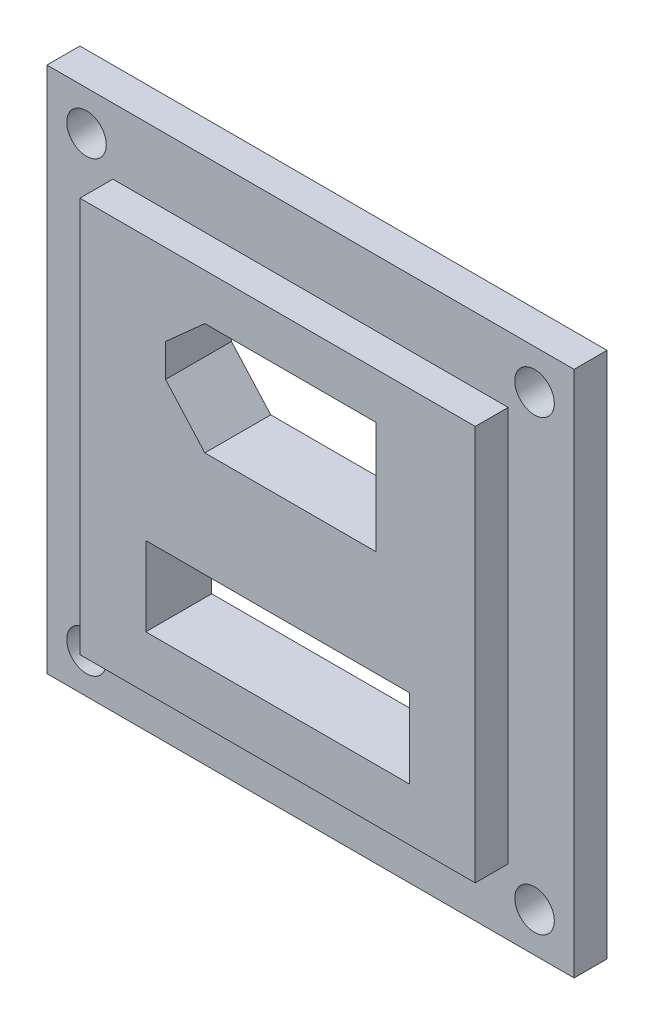
from build123d import *

# Parameters (mm, degrees)
SKETCH1_W           = 40
SKETCH1_H           = 40
BOSS_EXTRUDE2_DEPTH = 2.5
SKETCH2_W           = 30
SKETCH2_H           = 30
BOSS_EXTRUDE3_DEPTH = 2.5
SKETCH3_R           = 1.5
CUT_EXTRUDE1_DEPTH  = 2.5
SKETCH4_W           = 20
SKETCH4_H           = 6
CUT_EXTRUDE2_DEPTH  = 5


with BuildPart() as part:
    # Sketch1 → Boss-Extrude2 (new body)
    with BuildSketch(Plane.XY):
        with Locations((20, 20)):
            Rectangle(SKETCH1_W, SKETCH1_H)
    extrude(amount=BOSS_EXTRUDE2_DEPTH)

    # Sketch2 → Boss-Extrude3 (add)
    with BuildSketch(Plane.XY.offset(2.5)):
        with Locations((20, 20)):
            Rectangle(SKETCH2_W, SKETCH2_H)
    extrude(amount=BOSS_EXTRUDE3_DEPTH)

    # Sketch3 → Cut-Extrude1 (cut)
    with BuildSketch(Plane.XY.offset(2.5)):
        with Locations((3, 37)):
            Circle(SKETCH3_R)
        with Locations((37, 37)):
            Circle(SKETCH3_R)
        with Locations((37, 3)):
            Circle(SKETCH3_R)
        with Locations((3, 3)):
            Circle(SKETCH3_R)
    extrude(amount=-CUT_EXTRUDE1_DEPTH, mode=Mode.SUBTRACT)

    # Sketch4 → Cut-Extrude2 (cut)
    with BuildSketch(Plane.XY.offset(5)):
        Polygon((27.48142397, 31.5), (14.48142397, 31.5), (11.5, 28.833333333), (11.5, 26.333333333), (14.48142397, 23), (27.48142397, 23), align=None)
        with Locations((20, 12)):
            Rectangle(SKETCH4_W, SKETCH4_H)
    extrude(amount=-CUT_EXTRUDE2_DEPTH, mode=Mode.SUBTRACT)


solid = part.part
